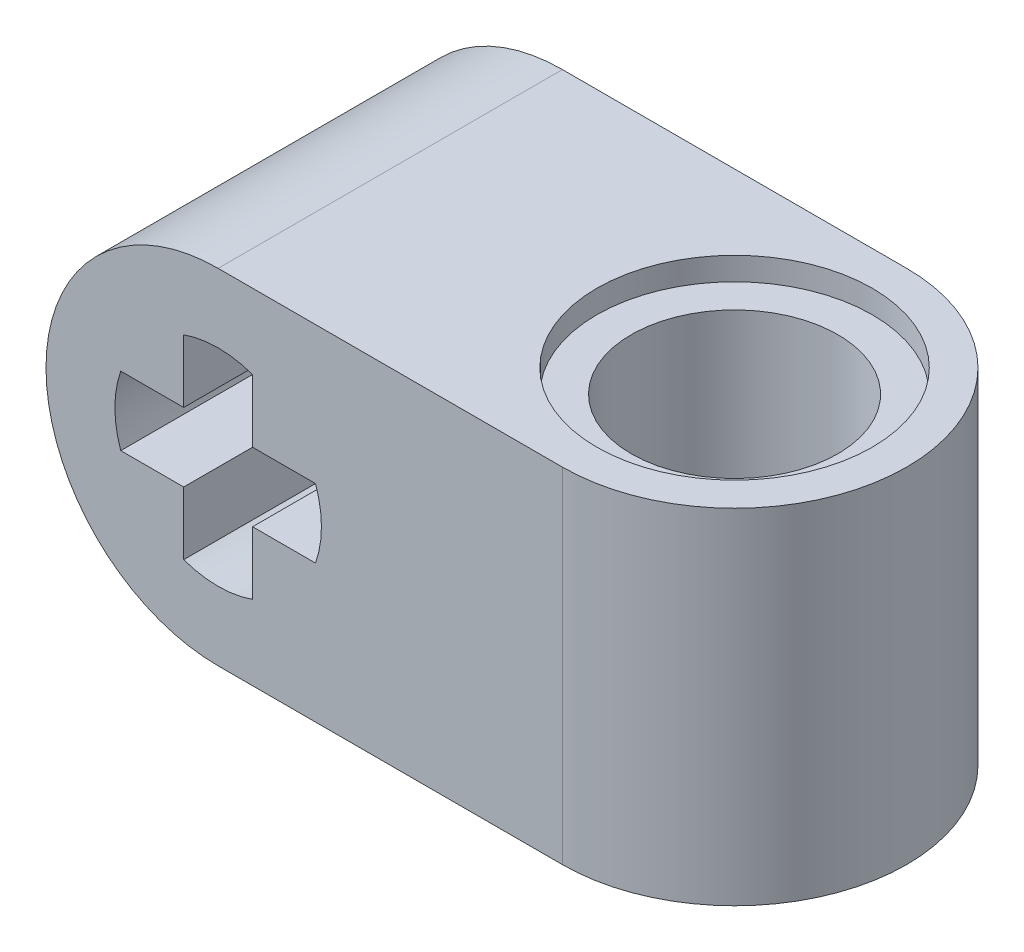
from build123d import *

# Parameters (mm, degrees)
SKETCH1_R           = 1.5
BOSS_EXTRUDE1_DEPTH = 5
SKETCH1_3_R         = 2
SKETCH1_3_R_2       = 1.5
CUT_EXTRUDE1_DEPTH  = 0.333333333
CUT_EXTRUDE2_START  = -0.333333333
SKETCH2_R           = 2
SKETCH2_R_2         = 1.5
CUT_EXTRUDE2_DEPTH  = 0.333333333
CUT_EXTRUDE3_REACH  = 10.66


with BuildPart() as part:
    # Sketch1 → Boss-Extrude1 (new body)
    with BuildSketch(Plane(origin=(0, 0, 0), x_dir=(1, 0, 0), z_dir=(0, 1, 0))):
        with BuildLine():
            Line((-5, 2.5), (-5, -2.5))
            Line((-5, -2.5), (2.5, -2.5))
            ThreePointArc((2.5, -2.5), (5, 0), (2.5, 2.5))
            Line((2.5, 2.5), (-5, 2.5))
        make_face()
        with Locations((2.5, 0)):
            Circle(SKETCH1_R, mode=Mode.SUBTRACT)
    extrude(amount=BOSS_EXTRUDE1_DEPTH)

    # Sketch1_3 → Cut-Extrude1 (cut)
    with BuildSketch(Plane(origin=(0, 0, 0), x_dir=(1, 0, 0), z_dir=(0, 1, 0))):
        with Locations((2.5, 0)):
            Circle(SKETCH1_3_R)
        with Locations((2.5, 0)):
            Circle(SKETCH1_3_R_2, mode=Mode.SUBTRACT)
    extrude(amount=CUT_EXTRUDE1_DEPTH, mode=Mode.SUBTRACT)

    # Sketch2 → Cut-Extrude2 (cut)
    with BuildSketch(Plane(origin=(0, 5, 0), x_dir=(1, 0, 0), z_dir=(0, 1, 0)).offset(CUT_EXTRUDE2_START)):
        with Locations((2.5, 0)):
            Circle(SKETCH2_R)
        with Locations((2.5, 0)):
            Circle(SKETCH2_R_2, mode=Mode.SUBTRACT)
    extrude(amount=CUT_EXTRUDE2_DEPTH, mode=Mode.SUBTRACT)

    # Sketch3 → Cut-Extrude3 (cut, up to next)
    with BuildSketch(Plane.XY.offset(2.5), mode=Mode.PRIVATE) as cut_extrude3_sk1:
        with BuildLine():
            Line((-2.5, 5), (-5, 5))
            Line((-5, 5), (-5, 2.5))
            ThreePointArc((-5, 2.5), (-4.267766953, 4.267766953), (-2.5, 5))
        make_face()
    cut_extrude3_tool1 = extrude(cut_extrude3_sk1.sketch, amount=-CUT_EXTRUDE3_REACH, mode=Mode.PRIVATE) & part.part
    # Sketch3 → Cut-Extrude3 (cut, up to next)
    with BuildSketch(Plane.XY.offset(2.5), mode=Mode.PRIVATE) as cut_extrude3_sk2:
        with BuildLine():
            ThreePointArc((-2.5, 0), (-4.267766953, 0.732233047), (-5, 2.5))
            Line((-5, 2.5), (-5, 0))
            Line((-5, 0), (-2.5, 0))
        make_face()
    cut_extrude3_tool2 = extrude(cut_extrude3_sk2.sketch, amount=-CUT_EXTRUDE3_REACH, mode=Mode.PRIVATE) & part.part
    # Sketch3 → Cut-Extrude3 (cut, up to next)
    with BuildSketch(Plane.XY.offset(2.5), mode=Mode.PRIVATE) as cut_extrude3_sk3:
        with BuildLine():
            ThreePointArc((-3, 1.085786438), (-2.5, 1), (-2, 1.085786438))
            Line((-2, 1.085786438), (-2, 2))
            Line((-2, 2), (-1.085786438, 2))
            ThreePointArc((-1.085786438, 2), (-1, 2.5), (-1.085786438, 3))
            Line((-1.085786438, 3), (-2, 3))
            Line((-2, 3), (-2, 3.914213562))
            ThreePointArc((-2, 3.914213562), (-2.5, 4), (-3, 3.914213562))
            Line((-3, 3.914213562), (-3, 3))
            Line((-3, 3), (-3.914213562, 3))
            ThreePointArc((-3.914213562, 3), (-4, 2.5), (-3.914213562, 2))
            Line((-3.914213562, 2), (-3, 2))
            Line((-3, 2), (-3, 1.085786438))
        make_face()
    cut_extrude3_tool3 = extrude(cut_extrude3_sk3.sketch, amount=-CUT_EXTRUDE3_REACH, mode=Mode.PRIVATE) & part.part
    add(cut_extrude3_tool1.solids().sort_by_distance((-4.44158, 4.44158, 2.5))[0], mode=Mode.SUBTRACT)
    add(cut_extrude3_tool2.solids().sort_by_distance((-4.44158, 0.55842, 2.5))[0], mode=Mode.SUBTRACT)
    add(cut_extrude3_tool3.solids().sort_by_distance((-2.5, 2.5, 2.5))[0], mode=Mode.SUBTRACT)


solid = part.part
